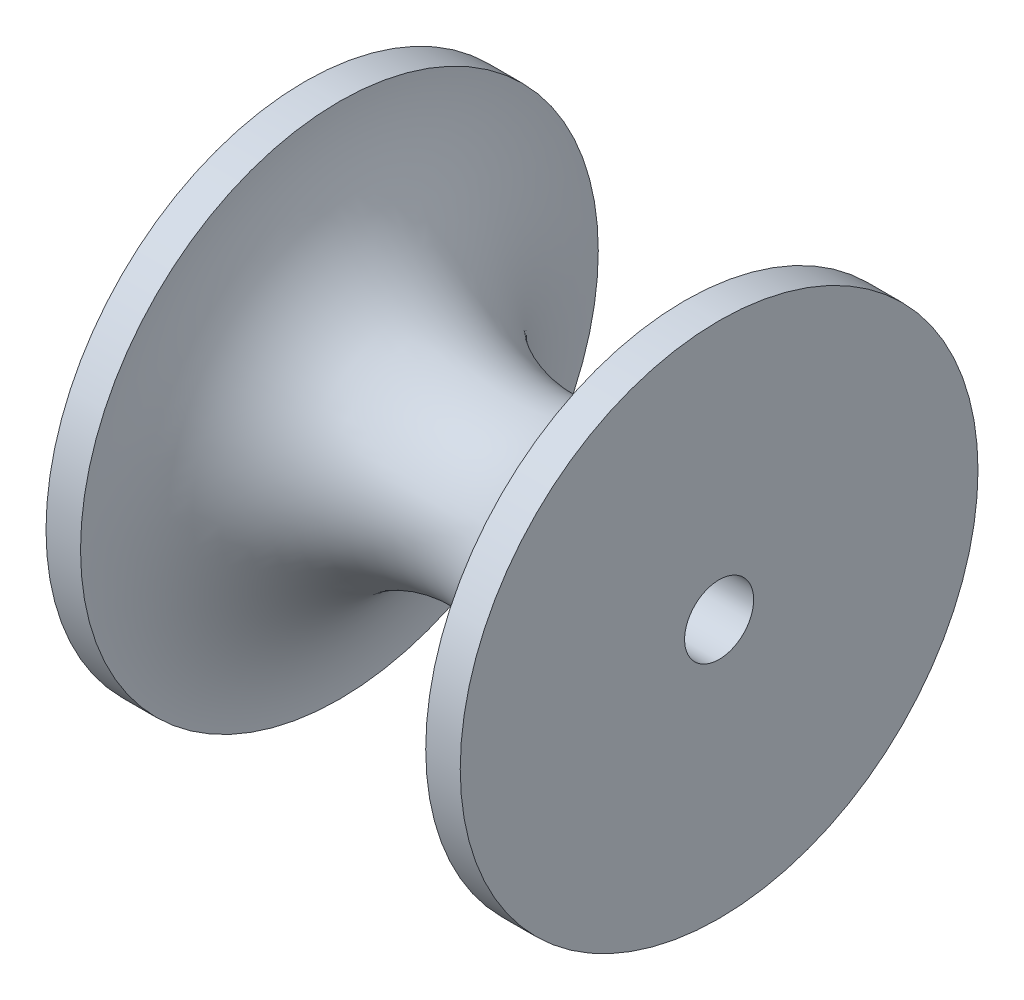
from build123d import *

# Parameters (mm, degrees)
SKETCH2_R          = 2
CUT_EXTRUDE1_DEPTH = 25


with BuildPart() as part:
    # Sketch1 → Revolve1 (revolve)
    with BuildSketch(Plane.XY):
        with BuildLine():
            Line((-10, -12.5), (10, -12.5))
            Line((10, -12.5), (12, -12.5))
            Line((12, -12.5), (12, 2.5))
            Line((12, 2.5), (10, 2.5))
            ThreePointArc((10, 2.5), (0, -7.5), (-10, 2.5))
            Line((-10, 2.5), (-12, 2.5))
            Line((-12, 2.5), (-12, -12.5))
            Line((-12, -12.5), (-10, -12.5))
        make_face()
    revolve(axis=Axis((-10, -12.5, 0), (1, 0, 0)))

    # Sketch2 → Cut-Extrude1 (cut, through all)
    with BuildSketch(Plane(origin=(12, 0, 0), x_dir=(0, 0, -1), z_dir=(1, 0, 0))):
        with Locations((0, -12.5)):
            Circle(SKETCH2_R)
    extrude(amount=-CUT_EXTRUDE1_DEPTH, mode=Mode.SUBTRACT)


solid = part.part
